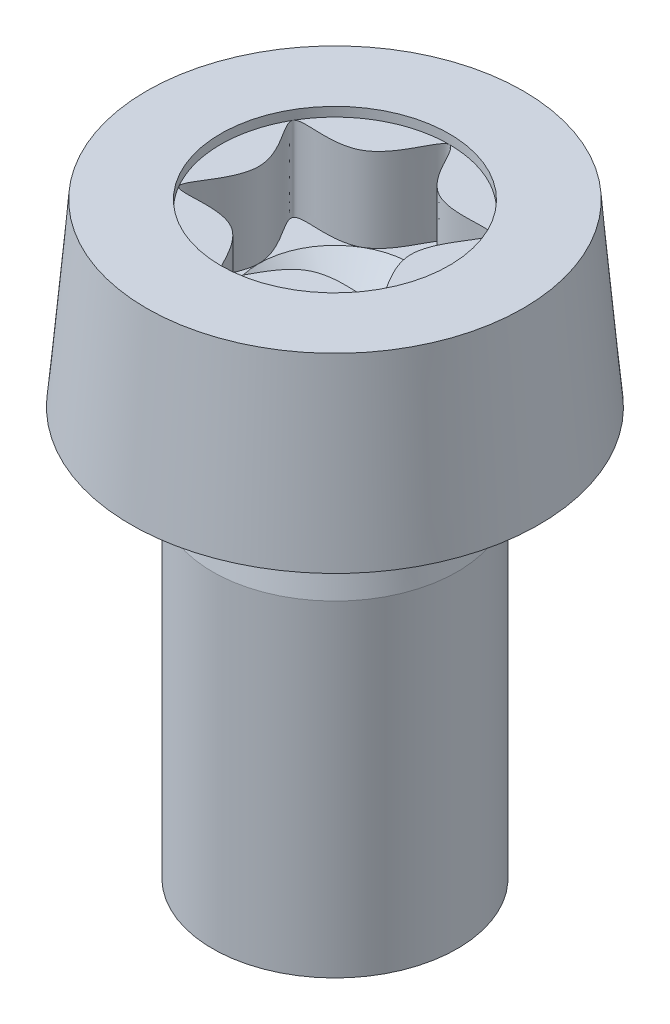
from build123d import *

# Parameters (mm, degrees)
FILLET1_R                 = 0.25
SOCKET_CUT_EXTRUDE1_DEPTH = 2.29
SKETCH3_R                 = 2.8
SOCKET_CUT_EXTRUDE2_DEPTH = 0.229


with BuildPart() as part:
    # Sketch1 → Body-Revolve (revolve)
    with BuildSketch(Plane.XY, mode=Mode.PRIVATE) as body_revolve_sk:
        Polygon((0, 14.4), (4.61504988, 14.4), (5, 10), (3, 10), (2.6, 10), (3, 8), (3, 0), (0, 0), align=None)
    revolve(body_revolve_sk.sketch.rotate(Axis((0, 0, 0), (0, 1, 0)), 90), axis=Axis((0, 0, 0), (0, 1, 0)))

    # Fillet1
    fillet1_edges = [part.edges().sort_by_distance(p)[0] for p in [
        (0, 10, 2.6),
    ]]
    fillet(fillet1_edges, radius=FILLET1_R)

    # Sketch2 → Socket-Cut-Extrude1 (cut)
    with BuildSketch(Plane(origin=(0, 14.4, 0), x_dir=(-1, 0, 0), z_dir=(0, 1, 0))):
        with BuildLine():
            add(Edge.make_bspline(
                [(0, -2.8), (-0.201301877, -2.8), (-0.603905632, -1.045995238), (-3.184377472, -1.838501191), (-1.207811264, 0), (-3.184377472, 1.838501191), (-0.603905632, 1.045995238), (0, 3.677002381), (0.603905632, 1.045995238), (3.184377472, 1.838501191), (1.207811264, 0), (3.184377472, -1.838501191), (0.603905632, -1.045995238), (0.201301877, -2.8), (0, -2.8)],
                knots=[0, 0, 0, 0, 0.083333333, 0.166666667, 0.25, 0.333333333, 0.416666667, 0.5, 0.583333333, 0.666666667, 0.75, 0.833333333, 0.916666667, 1, 1, 1, 1], degree=3))
        make_face()
    extrude(amount=-SOCKET_CUT_EXTRUDE1_DEPTH, mode=Mode.SUBTRACT)

    # Sketch3 → Socket-Cut-Extrude2 (cut)
    with BuildSketch(Plane(origin=(0, 14.4, 0), x_dir=(-1, 0, 0), z_dir=(0, 1, 0))):
        with Locations(Location((0, 0, 0), (0, 0, 90))):
            Circle(SKETCH3_R)
    extrude(amount=-SOCKET_CUT_EXTRUDE2_DEPTH, mode=Mode.SUBTRACT)

    # Sketch4 → Drill-Cut-Revolve (revolve, cut)
    with BuildSketch(Plane.XY, mode=Mode.PRIVATE) as drill_cut_revolve_sk:
        Polygon((0, 12.11), (1.866666667, 12.11), (0, 10.44), align=None)
    revolve(drill_cut_revolve_sk.sketch.rotate(Axis((0, 0, 0), (0, 1, 0)), 270), axis=Axis((0, 0, 0), (0, 1, 0)), mode=Mode.SUBTRACT)


solid = part.part
